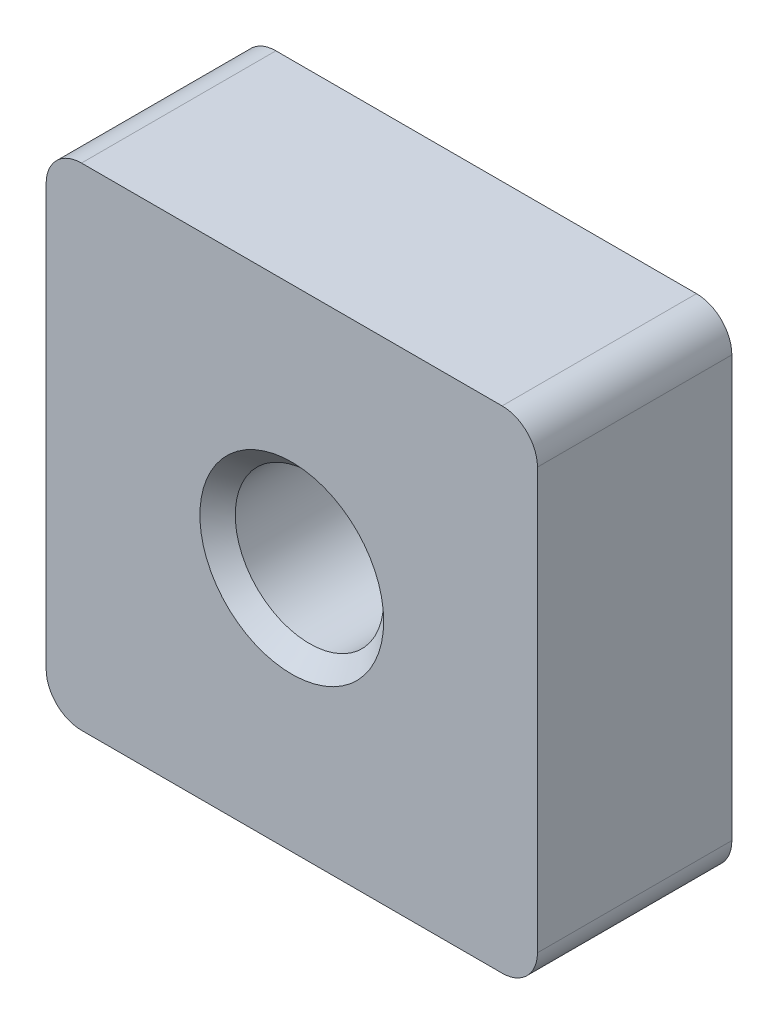
from build123d import *

# Parameters (mm, degrees)
SKETCH_1_W      = 13.9
SKETCH_1_H      = 13.9
EXTRUDE_1_DEPTH = 5.5
FILLET_1_R      = 1


with BuildPart() as part:
    # Эскиз1 → Бобышка-Вытянуть1 (new body)
    with BuildSketch(Plane.XY):
        Rectangle(SKETCH_1_W, SKETCH_1_H)
    extrude(amount=EXTRUDE_1_DEPTH)

    # Эскиз3 → Отверстие обработанное метчиком M52 (revolve, cut)
    with BuildSketch(Plane(origin=(0, 0, 5.5), x_dir=(0, -1, 0), z_dir=(1, 0, 0))):
        Polygon((0, 0), (0, 5.5), (2.6, 5.5), (2.1, 5), (2.1, 0.5), (2.6, 0), align=None)
    revolve(axis=Axis((0, 0, 11.85), (0, 0, -1)), mode=Mode.SUBTRACT)

    # Скругление1
    fillet_1_edges = [part.edges().sort_by_distance(p)[0] for p in [
        (6.95, -6.95, 2.75),
        (-6.95, -6.95, 2.75),
        (-6.95, 6.95, 2.75),
        (6.95, 6.95, 2.75),
    ]]
    fillet(fillet_1_edges, radius=FILLET_1_R)


solid = part.part
